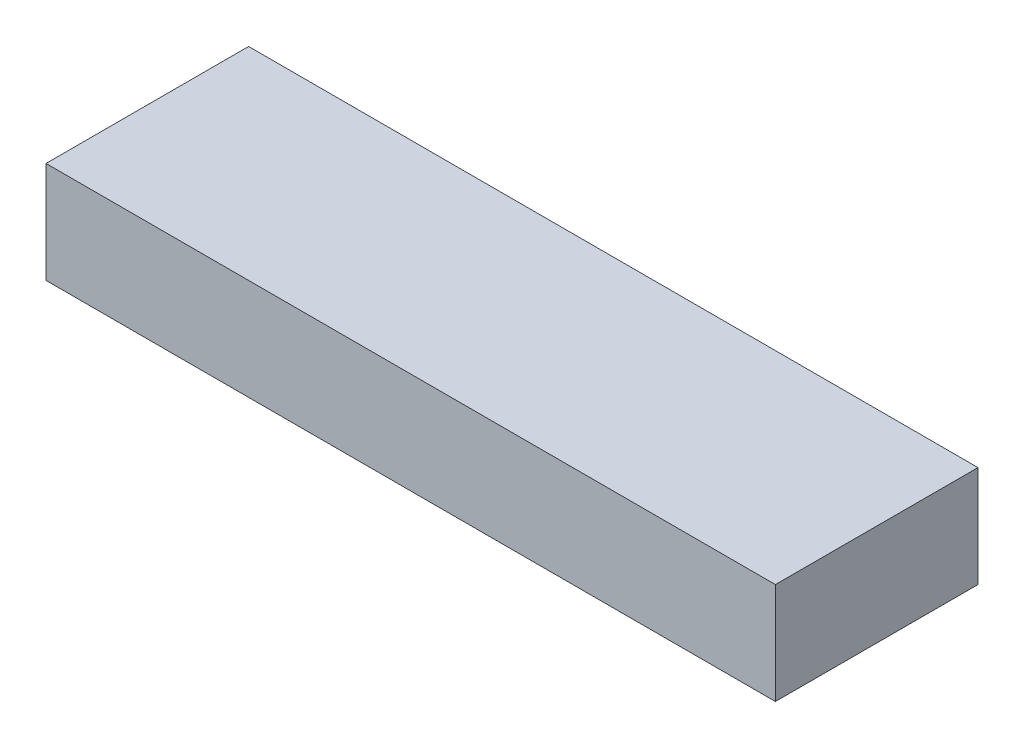
from build123d import *

# Parameters (mm, degrees)
ESBO_O1_W                = 180
ESBO_O1_H                = 50
RESSALTO_EXTRUS_O1_DEPTH = 25


with BuildPart() as part:
    # Esboço1 → Ressalto-extrusão1 (new body)
    with BuildSketch(Plane(origin=(0, 0, 0), x_dir=(1, 0, 0), z_dir=(0, 1, 0))):
        Rectangle(ESBO_O1_W, ESBO_O1_H)
    extrude(amount=RESSALTO_EXTRUS_O1_DEPTH)


solid = part.part
